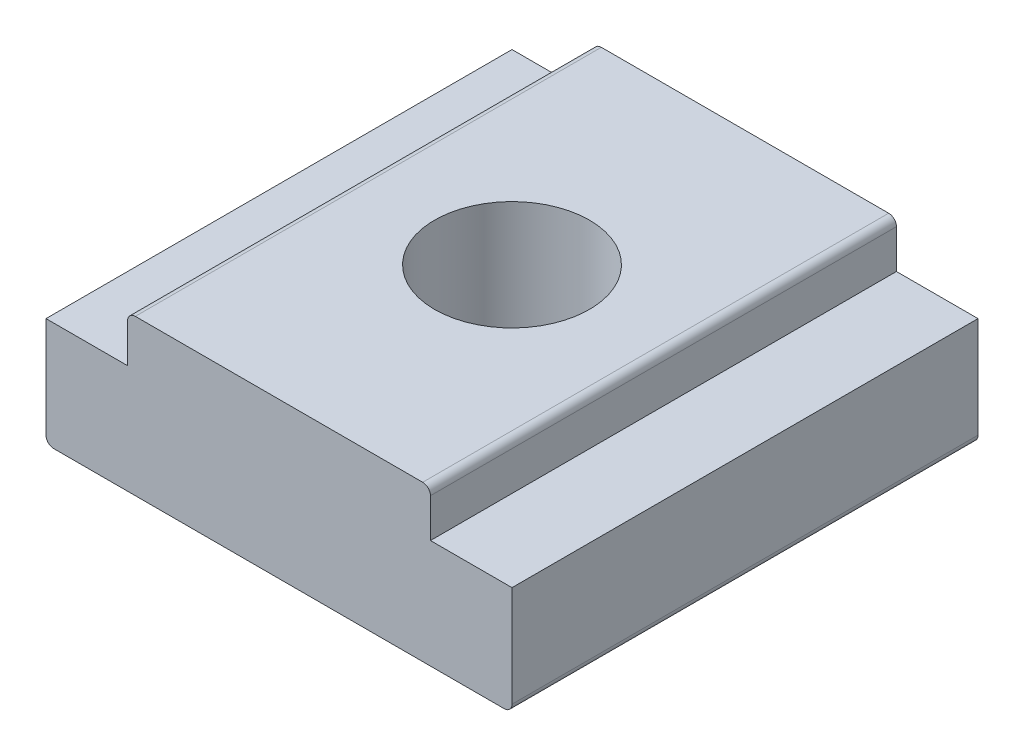
from build123d import *

# Parameters (mm, degrees)
BOSS_EXTRUDE1_DEPTH = 23.8125
SKETCH2_R           = 7.9121
CUT_EXTRUDE1_DEPTH  = 16.875
FILLET1_R           = 0.79375


with BuildPart() as part:
    # Sketch1 → Boss-Extrude1 (new body, symmetric)
    with BuildSketch(Plane.XY):
        Polygon((15.478125, 15.875), (-15.478125, 15.875), (-15.478125, 11.1125), (-23.8125, 11.1125), (-23.8125, 0), (23.8125, 0), (23.8125, 11.1125), (15.478125, 11.1125), align=None)
    extrude(amount=BOSS_EXTRUDE1_DEPTH, both=True)

    # Sketch2 → Cut-Extrude1 (cut, through all)
    with BuildSketch(Plane(origin=(0, 15.875, 0), x_dir=(1, 0, 0), z_dir=(0, 1, 0))):
        Circle(SKETCH2_R)
    extrude(amount=-CUT_EXTRUDE1_DEPTH, mode=Mode.SUBTRACT)

    # Fillet1
    fillet1_edges = [part.edges().sort_by_distance(p)[0] for p in [
        (-23.8125, 0, 0),
        (-15.478125, 15.875, 0),
        (15.478125, 15.875, 0),
        (23.8125, 0, 0),
    ]]
    fillet(fillet1_edges, radius=FILLET1_R)


solid = part.part
